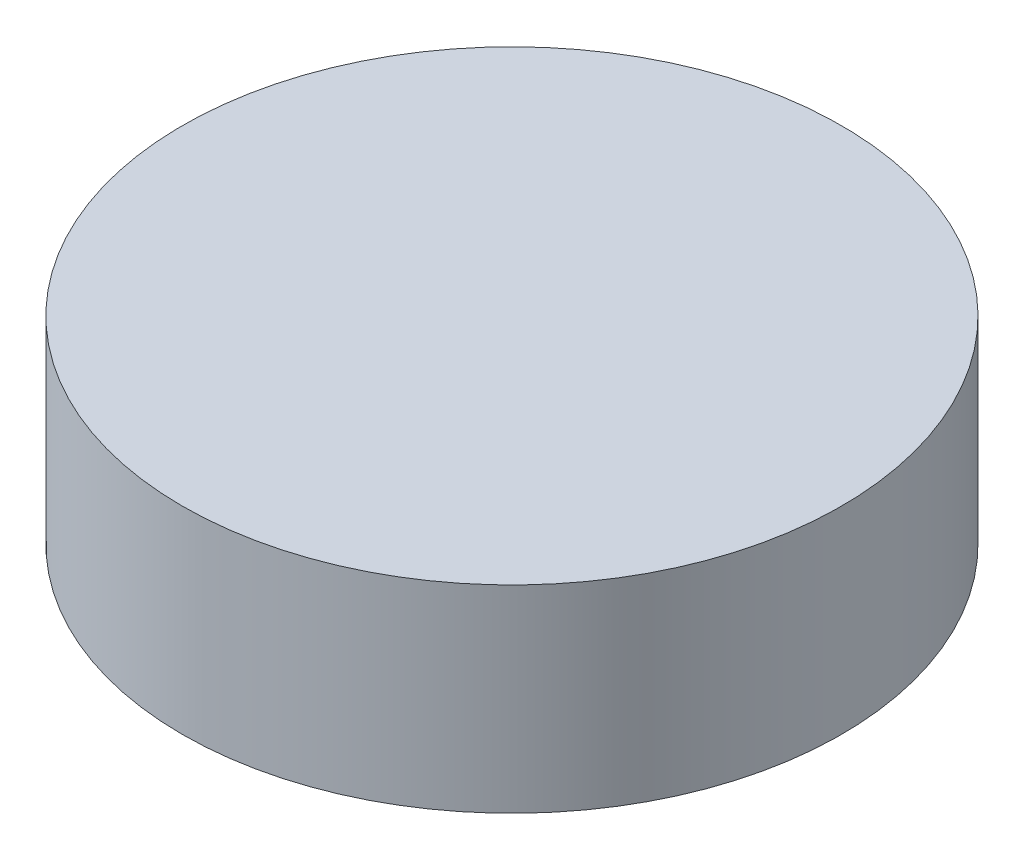
from build123d import *

# Parameters (mm, degrees)
SKETCH_1_R      = 5
EXTRUDE_1_DEPTH = 3


with BuildPart() as part:
    # 스케치1 → 보스-돌출1 (new body)
    with BuildSketch(Plane(origin=(0, 0, 0), x_dir=(1, 0, 0), z_dir=(0, 1, 0))):
        with Locations((-82.908270094, 25.809397513)):
            Circle(SKETCH_1_R)
    extrude(amount=EXTRUDE_1_DEPTH)


solid = part.part
